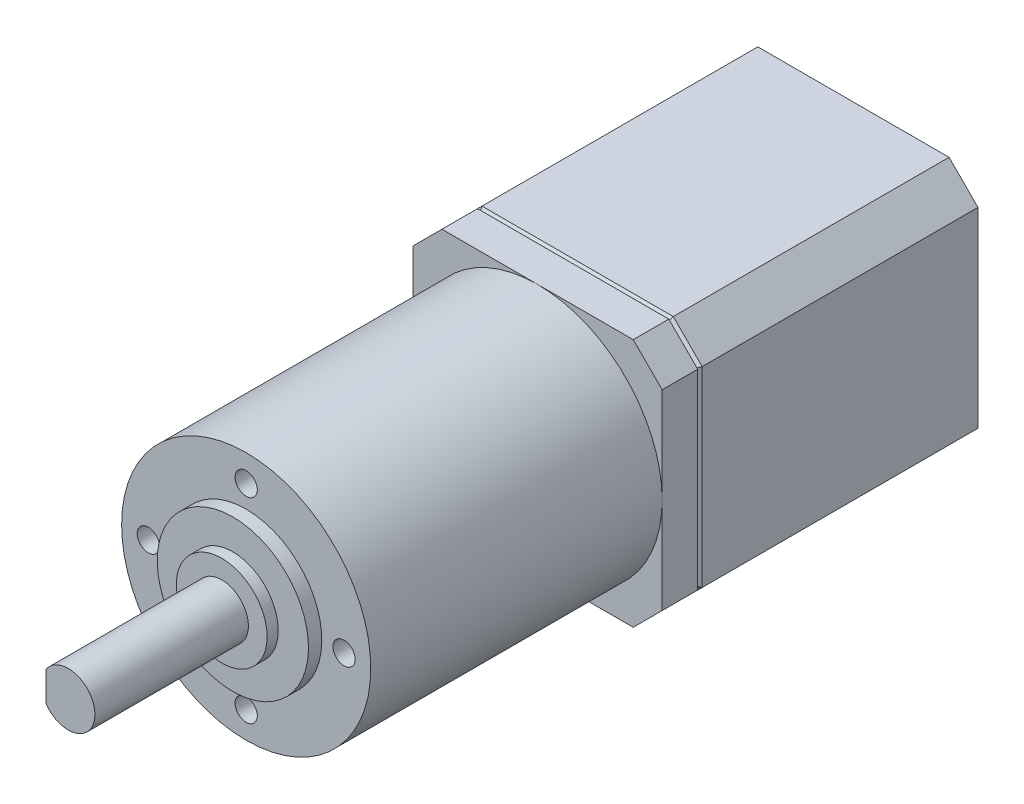
from build123d import *

# Parameters (mm, degrees)
BOSS_EXTRUDE1_DEPTH            = 31.5
BOSS_EXTRUDE2_DEPTH            = 4
CHAMFER1_SIZE                  = 0.5
M3X0_5_TAPPED_HOLE1_AT_2_COUNT = 2
M3X0_5_TAPPED_HOLE1_AT_2_PITCH = 15.556349186
M3X0_5_TAPPED_HOLE1_AT_3_COUNT = 2
M3X0_5_TAPPED_HOLE1_AT_3_PITCH = 22
M3X0_5_TAPPED_HOLE1_AT_4_COUNT = 2
M3X0_5_TAPPED_HOLE1_AT_4_PITCH = 15.556349186
SKETCH8_R                      = 5.1
SKETCH8_R_2                    = 3
BOSS_EXTRUDE3_DEPTH            = 1.25
CUT_EXTRUDE1_DEPTH             = 15


with BuildPart() as part:
    # Sketch1 → Boss-Extrude1 (new body)
    with BuildSketch(Plane.XY):
        Polygon((10.75, -14), (-10.75, -14), (-14, -10.75), (-14, 10.75), (-10.75, 14), (10.75, 14), (14, 10.75), (14, -10.75), align=None)
    extrude(amount=BOSS_EXTRUDE1_DEPTH)

    # Chamfer1
    chamfer1_edges = [part.edges().sort_by_distance(p)[0] for p in [
        (-12.375, 12.375, 31.5),
        (-14, 0, 31.5),
        (-12.375, -12.375, 31.5),
        (0, -14, 31.5),
        (12.375, -12.375, 31.5),
        (14, 0, 31.5),
        (12.375, 12.375, 31.5),
        (0, 14, 31.5),
    ]]
    chamfer(chamfer1_edges, length=CHAMFER1_SIZE)


with BuildPart() as body_2:
    # Sketch3 → Boss-Extrude2 (new body)
    with BuildSketch(Plane.XY.offset(31.5)):
        Polygon((14, 10.75), (10.75, 14), (-10.75, 14), (-14, 10.75), (-14, -10.75), (-10.75, -14), (10.75, -14), (14, -10.75), align=None)
    extrude(amount=BOSS_EXTRUDE2_DEPTH)

    # Sketch4 → Revolve1 (revolve)
    with BuildSketch(Plane(origin=(0, 0, 0), x_dir=(0, 0, -1), z_dir=(1, 0, 0))):
        Polygon((-88.25, 0), (-88.25, 3), (-69.75, 3), (-69.75, 8.5), (-68.25, 8.5), (-68.25, 14), (-35.5, 14), (-35.5, 0), align=None)
    revolve(axis=Axis((0, 0, 35.5), (0, 0, 1)))

    # Sketch7 → M3x0.5 Tapped Hole1 (revolve, cut)
    with BuildSketch(Plane(origin=(0, 11, 68.25), x_dir=(0, -1, 0), z_dir=(1, 0, 0))):
        Polygon((0, 0), (0, 5.751075774), (1.25, 5), (1.25, 0), align=None)
    m3x0_5_tapped_hole1 = revolve(axis=Axis((0, 11, 74.6), (0, 0, -1)), mode=Mode.SUBTRACT)

    # M3x0.5 Tapped Hole1 at 2: M3x0.5 Tapped Hole1 ×2
    with Locations(*[Vector(0.707106781, -0.707106781, 0) * (i * M3X0_5_TAPPED_HOLE1_AT_2_PITCH) for i in range(1, M3X0_5_TAPPED_HOLE1_AT_2_COUNT)]):
        add(m3x0_5_tapped_hole1, mode=Mode.SUBTRACT)

    # M3x0.5 Tapped Hole1 at 3: M3x0.5 Tapped Hole1 ×2
    with Locations(*[(0, -i * M3X0_5_TAPPED_HOLE1_AT_3_PITCH, 0) for i in range(1, M3X0_5_TAPPED_HOLE1_AT_3_COUNT)]):
        add(m3x0_5_tapped_hole1, mode=Mode.SUBTRACT)

    # M3x0.5 Tapped Hole1 at 4: M3x0.5 Tapped Hole1 ×2
    with Locations(*[Vector(-0.707106781, -0.707106781, 0) * (i * M3X0_5_TAPPED_HOLE1_AT_4_PITCH) for i in range(1, M3X0_5_TAPPED_HOLE1_AT_4_COUNT)]):
        add(m3x0_5_tapped_hole1, mode=Mode.SUBTRACT)

    # Sketch8 → Boss-Extrude3 (add)
    with BuildSketch(Plane.XY.offset(69.75)):
        Circle(SKETCH8_R)
        Circle(SKETCH8_R_2, mode=Mode.SUBTRACT)
    extrude(amount=BOSS_EXTRUDE3_DEPTH)

    # Sketch9 → Cut-Extrude1 (cut)
    with BuildSketch(Plane.XY.offset(88.25)):
        with BuildLine():
            Line((-2.5, 1.658312395), (-2.5, -1.658312395))
            ThreePointArc((-2.5, -1.658312395), (-3, 0), (-2.5, 1.658312395))
        make_face()
    extrude(amount=-CUT_EXTRUDE1_DEPTH, mode=Mode.SUBTRACT)


solid = Compound([part.part, body_2.part])
